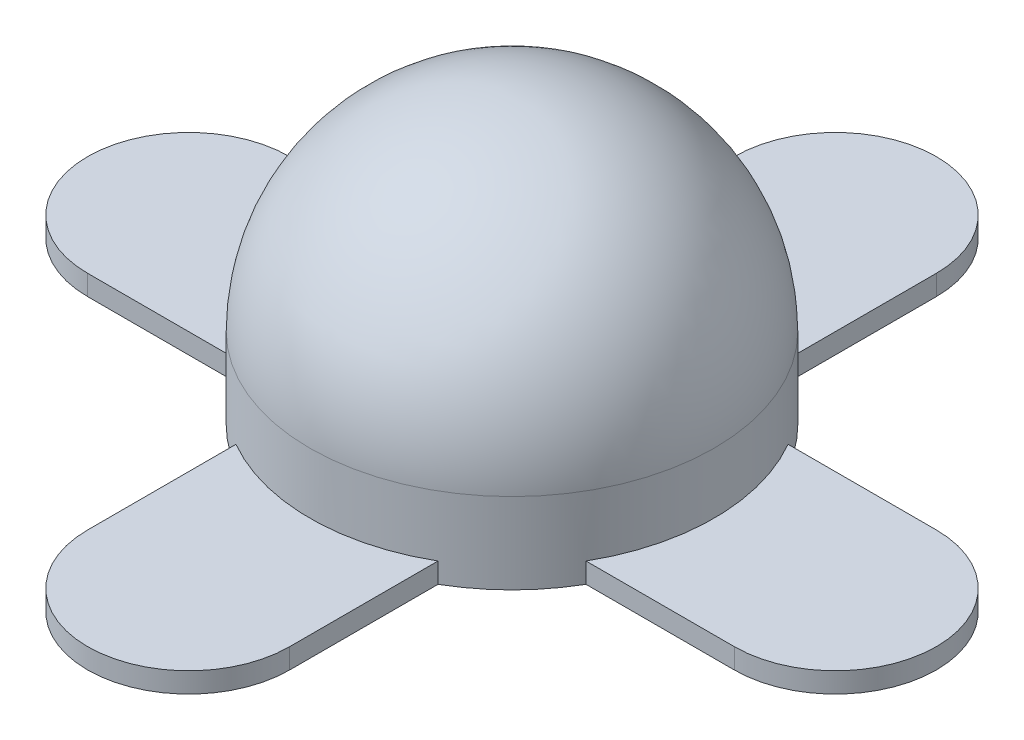
from build123d import *

# Parameters (mm, degrees)
SKETCH1_R           = 5
BOSS_EXTRUDE1_DEPTH = 7
FILLET1_R           = 5
BOSS_EXTRU_1_DEPTH  = 0.5


with BuildPart() as part:
    # Sketch1 → Boss-Extrude1 (new body)
    with BuildSketch(Plane(origin=(0, 0, 0), x_dir=(1, 0, 0), z_dir=(0, 1, 0))):
        Circle(SKETCH1_R)
    extrude(amount=BOSS_EXTRUDE1_DEPTH)

    # Fillet1
    fillet1_edges = [part.edges().sort_by_distance(p)[0] for p in [
        (-5, 7, 0),
    ]]
    fillet(fillet1_edges, radius=FILLET1_R)

    # Esquisse1 → Boss.-Extru.1 (add)
    with BuildSketch(Plane.XZ):
        with BuildLine():
            Line((-2.5, 8), (-2.5, 4.330127019))
            ThreePointArc((-2.5, 4.330127019), (0, 5), (2.5, 4.330127019))
            Line((2.5, 4.330127019), (2.5, 8))
            ThreePointArc((2.5, 8), (0, 10.5), (-2.5, 8))
        make_face()
        with BuildLine():
            ThreePointArc((-4.330127019, -2.5), (-5, 0), (-4.330127019, 2.5))
            Line((-4.330127019, 2.5), (-8, 2.5))
            ThreePointArc((-8, 2.5), (-10.5, 0), (-8, -2.5))
            Line((-8, -2.5), (-4.330127019, -2.5))
        make_face()
        with BuildLine():
            Line((8, 2.5), (4.330127019, 2.5))
            ThreePointArc((4.330127019, 2.5), (5, 0), (4.330127019, -2.5))
            Line((4.330127019, -2.5), (8, -2.5))
            ThreePointArc((8, -2.5), (10.5, 0), (8, 2.5))
        make_face()
        with BuildLine():
            ThreePointArc((2.5, -4.330127019), (0, -5), (-2.5, -4.330127019))
            Line((-2.5, -4.330127019), (-2.5, -8))
            ThreePointArc((-2.5, -8), (0, -10.5), (2.5, -8))
            Line((2.5, -8), (2.5, -4.330127019))
        make_face()
    extrude(amount=-BOSS_EXTRU_1_DEPTH)


solid = part.part
